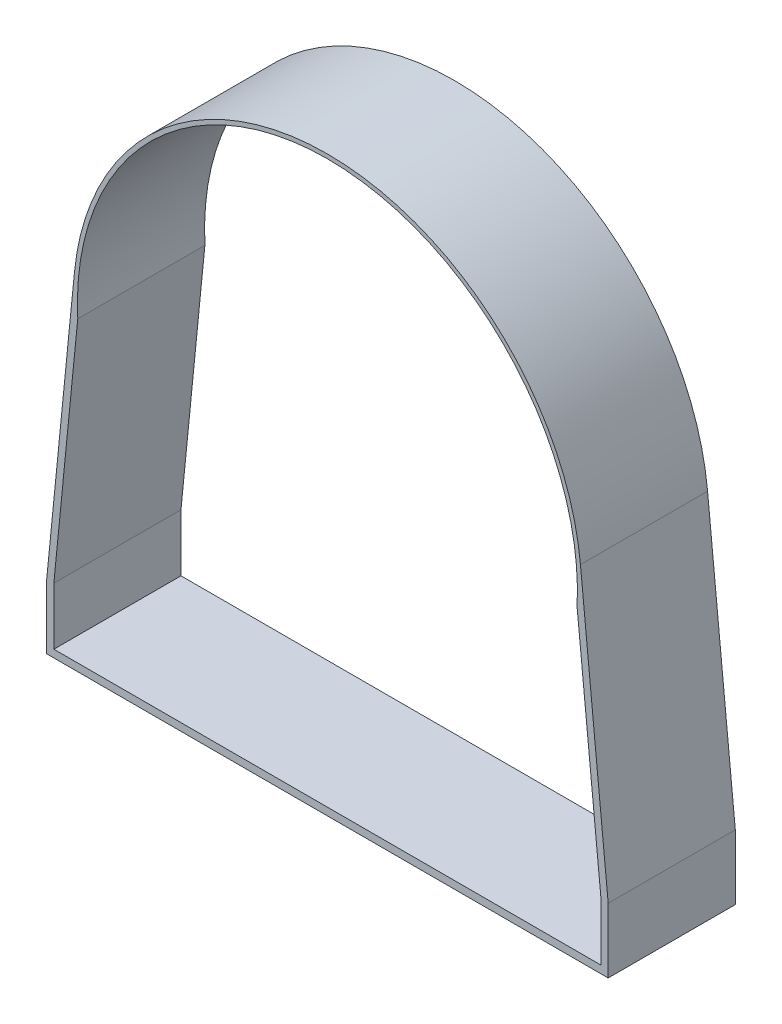
from build123d import *

# Parameters (mm, degrees)
BOSS_EXTRUDE1_DEPTH = 19.05


with BuildPart() as part:
    # Sketch1 → Boss-Extrude1 (new body)
    with BuildSketch(Plane.XY):
        with BuildLine():
            Line((-37.913782616, 3.762324776), (-42.067935824, -38.1))
            Line((-42.067935824, -38.1), (-42.067935824, -47.807493339))
            Line((-42.067935824, -47.807493339), (42.067935824, -47.807493339))
            Line((42.067935824, -47.807493339), (42.067935824, -38.1))
            Line((42.067935824, -38.1), (37.913782616, 3.762324776))
            ThreePointArc((37.913782616, 3.762324776), (0, 38.1), (-37.913782616, 3.762324776))
        make_face()
        with BuildLine():
            Line((-37.412264152, -1.987137644), (-40.995876955, -38.1))
            Line((-40.995876955, -38.1), (-40.995876955, -46.6725))
            Line((-40.995876955, -46.6725), (40.995876955, -46.6725))
            Line((40.995876955, -46.6725), (40.995876955, -38.099992109))
            Line((40.995876955, -38.099992109), (37.412264425, -1.987132504))
            ThreePointArc((37.412264425, -1.987132504), (-2.574e-06, 37.465), (-37.412264152, -1.987137644))
        make_face(mode=Mode.SUBTRACT)
    extrude(amount=BOSS_EXTRUDE1_DEPTH)


solid = part.part
